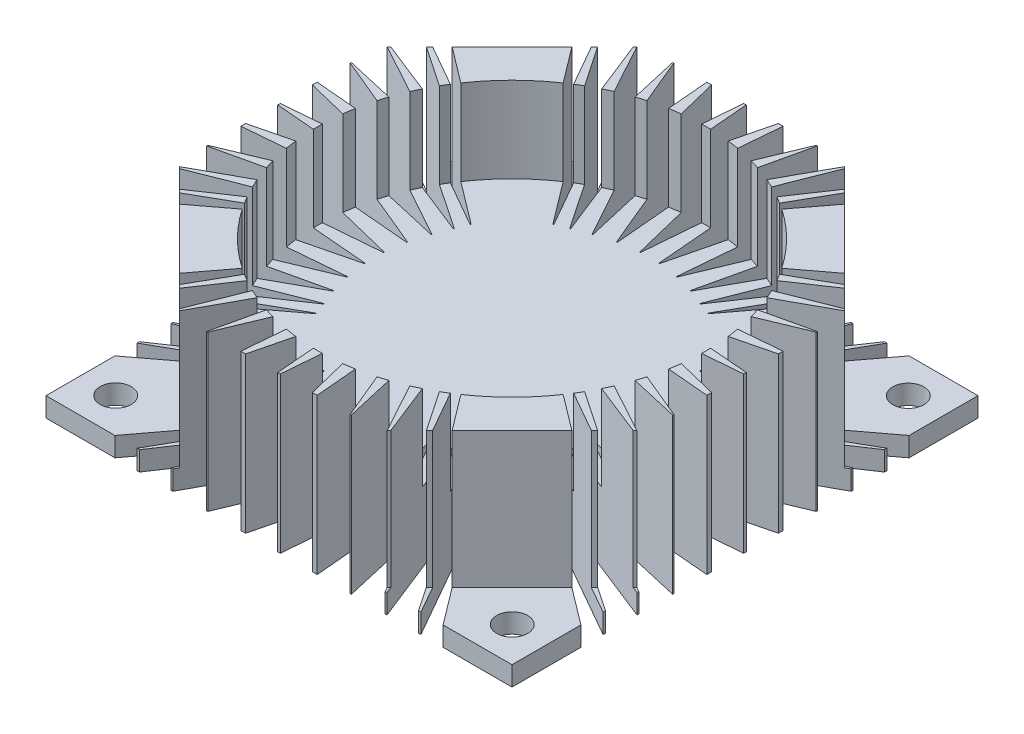
from build123d import *

# Parameters (mm, degrees)
SKETCH_1_W           = 60
SKETCH_1_H           = 60
EXTRUDE_1_DEPTH      = 20
CUT_EXTRUDE_1_DEPTH  = 17.5
SKETCH_3_R           = 25
CUT_EXTRUDE_2_DEPTH  = 11
CUT_EXTRUDE_11_DEPTH = 21
SKETCH_8_R           = 2
CUT_EXTRUDE_12_DEPTH = 21


with BuildPart() as part:
    # 草图1 → 凸台-拉伸1 (new body)
    with BuildSketch(Plane(origin=(0, 0, 0), x_dir=(1, 0, 0), z_dir=(0, 1, 0))):
        Rectangle(SKETCH_1_W, SKETCH_1_H)
    extrude(amount=EXTRUDE_1_DEPTH)

    # 草图2 → 切除-拉伸1 (cut)
    with BuildSketch(Plane(origin=(0, 20, 0), x_dir=(1, 0, 0), z_dir=(0, 1, 0))):
        Polygon((30, 30), (12.78, 30), (30, 12.78), align=None)
        Polygon((12.78, -30), (30, -12.78), (30, -30), align=None)
        Polygon((-30, -30), (-12.78, -30), (-30, -12.78), align=None)
        Polygon((-12.78, 30), (-30, 12.78), (-30, 30), align=None)
    extrude(amount=-CUT_EXTRUDE_1_DEPTH, mode=Mode.SUBTRACT)

    # 草图3 → 切除-拉伸2 (cut)
    with BuildSketch(Plane(origin=(0, 20, 0), x_dir=(1, 0, 0), z_dir=(0, 1, 0))):
        Circle(SKETCH_3_R)
    extrude(amount=-CUT_EXTRUDE_2_DEPTH, mode=Mode.SUBTRACT)

    # 草图5 → 切除-拉伸11 (cut, through all)
    with BuildSketch(Plane.XZ):
        with BuildLine():
            Line((30, -21.13), (15.28334495, -10.008208706))
            ThreePointArc((15.28334495, -10.008208706), (15.271732528, -9.940818999), (15.338228823, -9.924867076))
            Line((15.338228823, -9.924867076), (30, -18.272100789))
            Line((30, -18.272100789), (30, -21.13))
        make_face()
        with BuildLine():
            Line((30, -17.960025279), (15.857242965, -8.424723657))
            ThreePointArc((15.857242965, -8.424723657), (15.840953058, -8.359970065), (15.903561069, -8.336761756))
            Line((15.903561069, -8.336761756), (30, -13.904092322))
            Line((30, -13.904092322), (30, -17.960025279))
        make_face()
        with BuildLine():
            Line((30, -13.675862354), (16.684019005, -6.360485903))
            ThreePointArc((16.684019005, -6.360485903), (16.661367841, -6.298867475), (16.719270271, -6.267928589))
            Line((16.719270271, -6.267928589), (30, -9.313660737))
            Line((30, -9.313660737), (30, -13.675862354))
        make_face()
        with BuildLine():
            Line((17.382108811, -3.913859601), (30, -9.170246868))
            Line((30, -9.170246868), (30, -4.914024052))
            Line((30, -4.914024052), (17.405671551, -3.817892671))
            ThreePointArc((17.405671551, -3.817892671), (17.352778485, -3.85578199), (17.382108811, -3.913859601))
        make_face()
        with BuildLine():
            Line((17.761713022, -1.186326346), (30, -0.161498517))
            Line((30, -0.161498517), (30, -4.303132886))
            Line((30, -4.303132886), (17.753919437, -1.284699004))
            ThreePointArc((17.753919437, -1.284699004), (17.716041573, -1.232203073), (17.761713022, -1.186326346))
        make_face()
        with BuildLine():
            Line((18.272100789, -30), (21.13, -30))
            Line((21.13, -30), (10.008208706, -15.28334495))
            ThreePointArc((10.008208706, -15.28334495), (9.940818999, -15.271732528), (9.924867076, -15.338228823))
            Line((9.924867076, -15.338228823), (18.272100789, -30))
        make_face()
        with BuildLine():
            Line((1.284699004, -17.753919437), (4.303132886, -30))
            Line((4.303132886, -30), (0.161498517, -30))
            Line((0.161498517, -30), (1.186326346, -17.761713022))
            ThreePointArc((1.186326346, -17.761713022), (1.232203073, -17.716041573), (1.284699004, -17.753919437))
        make_face()
        with BuildLine():
            Line((3.913859601, -17.382108811), (9.170246868, -30))
            Line((9.170246868, -30), (4.914024052, -30))
            Line((4.914024052, -30), (3.817892671, -17.405671551))
            ThreePointArc((3.817892671, -17.405671551), (3.85578199, -17.352778485), (3.913859601, -17.382108811))
        make_face()
        with BuildLine():
            Line((6.267928589, -16.719270271), (9.313660737, -30))
            Line((9.313660737, -30), (13.675862354, -30))
            Line((13.675862354, -30), (6.360485903, -16.684019005))
            ThreePointArc((6.360485903, -16.684019005), (6.298867475, -16.661367841), (6.267928589, -16.719270271))
        make_face()
        with BuildLine():
            Line((8.336761756, -15.903561069), (13.904092322, -30))
            Line((13.904092322, -30), (17.960025279, -30))
            Line((17.960025279, -30), (8.424723657, -15.857242965))
            ThreePointArc((8.424723657, -15.857242965), (8.359970065, -15.840953058), (8.336761756, -15.903561069))
        make_face()
        with BuildLine():
            Line((-17.753919437, -1.284699004), (-30, -4.303132886))
            Line((-30, -4.303132886), (-30, -0.161498517))
            Line((-30, -0.161498517), (-17.761713022, -1.186326346))
            ThreePointArc((-17.761713022, -1.186326346), (-17.716041573, -1.232203073), (-17.753919437, -1.284699004))
        make_face()
        with BuildLine():
            Line((-17.382108811, -3.913859601), (-30, -9.170246868))
            Line((-30, -9.170246868), (-30, -4.914024052))
            Line((-30, -4.914024052), (-17.405671551, -3.817892671))
            ThreePointArc((-17.405671551, -3.817892671), (-17.352778485, -3.85578199), (-17.382108811, -3.913859601))
        make_face()
        with BuildLine():
            Line((-16.719270271, -6.267928589), (-30, -9.313660737))
            Line((-30, -9.313660737), (-30, -13.675862354))
            Line((-30, -13.675862354), (-16.684019005, -6.360485903))
            ThreePointArc((-16.684019005, -6.360485903), (-16.661367841, -6.298867475), (-16.719270271, -6.267928589))
        make_face()
        with BuildLine():
            Line((-15.903561069, -8.336761756), (-30, -13.904092322))
            Line((-30, -13.904092322), (-30, -17.960025279))
            Line((-30, -17.960025279), (-15.857242965, -8.424723657))
            ThreePointArc((-15.857242965, -8.424723657), (-15.840953058, -8.359970065), (-15.903561069, -8.336761756))
        make_face()
        with BuildLine():
            Line((-30, -18.272100789), (-30, -21.13))
            Line((-30, -21.13), (-15.28334495, -10.008208706))
            ThreePointArc((-15.28334495, -10.008208706), (-15.271732528, -9.940818999), (-15.338228823, -9.924867076))
            Line((-15.338228823, -9.924867076), (-30, -18.272100789))
        make_face()
        with BuildLine():
            Line((-9.924867076, -15.338228823), (-18.272100789, -30))
            Line((-18.272100789, -30), (-21.13, -30))
            Line((-21.13, -30), (-10.008208706, -15.28334495))
            ThreePointArc((-10.008208706, -15.28334495), (-9.940818999, -15.271732528), (-9.924867076, -15.338228823))
        make_face()
        with BuildLine():
            Line((-17.960025279, -30), (-8.424723657, -15.857242965))
            ThreePointArc((-8.424723657, -15.857242965), (-8.359970065, -15.840953058), (-8.336761756, -15.903561069))
            Line((-8.336761756, -15.903561069), (-13.904092322, -30))
            Line((-13.904092322, -30), (-17.960025279, -30))
        make_face()
        with BuildLine():
            Line((-13.675862354, -30), (-6.360485903, -16.684019005))
            ThreePointArc((-6.360485903, -16.684019005), (-6.298867475, -16.661367841), (-6.267928589, -16.719270271))
            Line((-6.267928589, -16.719270271), (-9.313660737, -30))
            Line((-9.313660737, -30), (-13.675862354, -30))
        make_face()
        with BuildLine():
            Line((-3.817892671, -17.405671551), (-4.914024052, -30))
            Line((-4.914024052, -30), (-9.170246868, -30))
            Line((-9.170246868, -30), (-3.913859601, -17.382108811))
            ThreePointArc((-3.913859601, -17.382108811), (-3.85578199, -17.352778485), (-3.817892671, -17.405671551))
        make_face()
        with BuildLine():
            Line((-1.186326346, -17.761713022), (-0.161498517, -30))
            Line((-0.161498517, -30), (-4.303132886, -30))
            Line((-4.303132886, -30), (-1.284699004, -17.753919437))
            ThreePointArc((-1.284699004, -17.753919437), (-1.232203073, -17.716041573), (-1.186326346, -17.761713022))
        make_face()
        with BuildLine():
            Line((17.753919437, 1.284699004), (30, 4.303132886))
            Line((30, 4.303132886), (30, 0.161498517))
            Line((30, 0.161498517), (17.761713022, 1.186326346))
            ThreePointArc((17.761713022, 1.186326346), (17.716041573, 1.232203073), (17.753919437, 1.284699004))
        make_face()
        with BuildLine():
            Line((17.382108811, 3.913859601), (30, 9.170246868))
            Line((30, 9.170246868), (30, 4.914024052))
            Line((30, 4.914024052), (17.405671551, 3.817892671))
            ThreePointArc((17.405671551, 3.817892671), (17.352778485, 3.85578199), (17.382108811, 3.913859601))
        make_face()
        with BuildLine():
            Line((16.719270271, 6.267928589), (30, 9.313660737))
            Line((30, 9.313660737), (30, 13.675862354))
            Line((30, 13.675862354), (16.684019005, 6.360485903))
            ThreePointArc((16.684019005, 6.360485903), (16.661367841, 6.298867475), (16.719270271, 6.267928589))
        make_face()
        with BuildLine():
            Line((15.903561069, 8.336761756), (30, 13.904092322))
            Line((30, 13.904092322), (30, 17.960025279))
            Line((30, 17.960025279), (15.857242965, 8.424723657))
            ThreePointArc((15.857242965, 8.424723657), (15.840953058, 8.359970065), (15.903561069, 8.336761756))
        make_face()
        with BuildLine():
            Line((30, 18.272100789), (30, 21.13))
            Line((30, 21.13), (15.28334495, 10.008208706))
            ThreePointArc((15.28334495, 10.008208706), (15.271732528, 9.940818999), (15.338228823, 9.924867076))
            Line((15.338228823, 9.924867076), (30, 18.272100789))
        make_face()
        with BuildLine():
            Line((9.924867076, 15.338228823), (18.272100789, 30))
            Line((18.272100789, 30), (21.13, 30))
            Line((21.13, 30), (10.008208706, 15.28334495))
            ThreePointArc((10.008208706, 15.28334495), (9.940818999, 15.271732528), (9.924867076, 15.338228823))
        make_face()
        with BuildLine():
            Line((17.960025279, 30), (8.424723657, 15.857242965))
            ThreePointArc((8.424723657, 15.857242965), (8.359970065, 15.840953058), (8.336761756, 15.903561069))
            Line((8.336761756, 15.903561069), (13.904092322, 30))
            Line((13.904092322, 30), (17.960025279, 30))
        make_face()
        with BuildLine():
            Line((13.675862354, 30), (6.360485903, 16.684019005))
            ThreePointArc((6.360485903, 16.684019005), (6.298867475, 16.661367841), (6.267928589, 16.719270271))
            Line((6.267928589, 16.719270271), (9.313660737, 30))
            Line((9.313660737, 30), (13.675862354, 30))
        make_face()
        with BuildLine():
            Line((3.817892671, 17.405671551), (4.914024052, 30))
            Line((4.914024052, 30), (9.170246868, 30))
            Line((9.170246868, 30), (3.913859601, 17.382108811))
            ThreePointArc((3.913859601, 17.382108811), (3.85578199, 17.352778485), (3.817892671, 17.405671551))
        make_face()
        with BuildLine():
            Line((1.186326346, 17.761713022), (0.161498517, 30))
            Line((0.161498517, 30), (4.303132886, 30))
            Line((4.303132886, 30), (1.284699004, 17.753919437))
            ThreePointArc((1.284699004, 17.753919437), (1.232203073, 17.716041573), (1.186326346, 17.761713022))
        make_face()
        with BuildLine():
            Line((-1.284699004, 17.753919437), (-4.303132886, 30))
            Line((-4.303132886, 30), (-0.161498517, 30))
            Line((-0.161498517, 30), (-1.186326346, 17.761713022))
            ThreePointArc((-1.186326346, 17.761713022), (-1.232203073, 17.716041573), (-1.284699004, 17.753919437))
        make_face()
        with BuildLine():
            Line((-3.913859601, 17.382108811), (-9.170246868, 30))
            Line((-9.170246868, 30), (-4.914024052, 30))
            Line((-4.914024052, 30), (-3.817892671, 17.405671551))
            ThreePointArc((-3.817892671, 17.405671551), (-3.85578199, 17.352778485), (-3.913859601, 17.382108811))
        make_face()
        with BuildLine():
            Line((-13.675862354, 30), (-6.360485903, 16.684019005))
            ThreePointArc((-6.360485903, 16.684019005), (-6.298867475, 16.661367841), (-6.267928589, 16.719270271))
            Line((-6.267928589, 16.719270271), (-9.313660737, 30))
            Line((-9.313660737, 30), (-13.675862354, 30))
        make_face()
        with BuildLine():
            Line((-17.960025279, 30), (-8.424723657, 15.857242965))
            ThreePointArc((-8.424723657, 15.857242965), (-8.359970065, 15.840953058), (-8.336761756, 15.903561069))
            Line((-8.336761756, 15.903561069), (-13.904092322, 30))
            Line((-13.904092322, 30), (-17.960025279, 30))
        make_face()
        with BuildLine():
            Line((-21.13, 30), (-10.008208706, 15.28334495))
            ThreePointArc((-10.008208706, 15.28334495), (-9.940818999, 15.271732528), (-9.924867076, 15.338228823))
            Line((-9.924867076, 15.338228823), (-18.272100789, 30))
            Line((-18.272100789, 30), (-21.13, 30))
        make_face()
        with BuildLine():
            Line((-15.338228823, 9.924867076), (-30, 18.272100789))
            Line((-30, 18.272100789), (-30, 21.13))
            Line((-30, 21.13), (-15.28334495, 10.008208706))
            ThreePointArc((-15.28334495, 10.008208706), (-15.271732528, 9.940818999), (-15.338228823, 9.924867076))
        make_face()
        with BuildLine():
            Line((-30, 17.960025279), (-15.857242965, 8.424723657))
            ThreePointArc((-15.857242965, 8.424723657), (-15.840953058, 8.359970065), (-15.903561069, 8.336761756))
            Line((-15.903561069, 8.336761756), (-30, 13.904092322))
            Line((-30, 13.904092322), (-30, 17.960025279))
        make_face()
        with BuildLine():
            Line((-30, 13.675862354), (-16.684019005, 6.360485903))
            ThreePointArc((-16.684019005, 6.360485903), (-16.661367841, 6.298867475), (-16.719270271, 6.267928589))
            Line((-16.719270271, 6.267928589), (-30, 9.313660737))
            Line((-30, 9.313660737), (-30, 13.675862354))
        make_face()
        with BuildLine():
            Line((-17.405671551, 3.817892671), (-30, 4.914024052))
            Line((-30, 4.914024052), (-30, 9.170246868))
            Line((-30, 9.170246868), (-17.382108811, 3.913859601))
            ThreePointArc((-17.382108811, 3.913859601), (-17.352778485, 3.85578199), (-17.405671551, 3.817892671))
        make_face()
        with BuildLine():
            Line((-17.761713022, 1.186326346), (-30, 0.161498517))
            Line((-30, 0.161498517), (-30, 4.303132886))
            Line((-30, 4.303132886), (-17.753919437, 1.284699004))
            ThreePointArc((-17.753919437, 1.284699004), (-17.716041573, 1.232203073), (-17.761713022, 1.186326346))
        make_face()
    extrude(amount=-CUT_EXTRUDE_11_DEPTH, mode=Mode.SUBTRACT)

    # 草图8 → 切除-拉伸12 (cut, through all)
    with BuildSketch(Plane.XZ):
        with Locations((25.52680918, 25.5)):
            Circle(SKETCH_8_R)
        with Locations((25.52680918, -25.5)):
            Circle(SKETCH_8_R)
        with Locations((-25.52680918, -25.5)):
            Circle(SKETCH_8_R)
        with Locations((-25.52680918, 25.5)):
            Circle(SKETCH_8_R)
    extrude(amount=-CUT_EXTRUDE_12_DEPTH, mode=Mode.SUBTRACT)


solid = part.part
